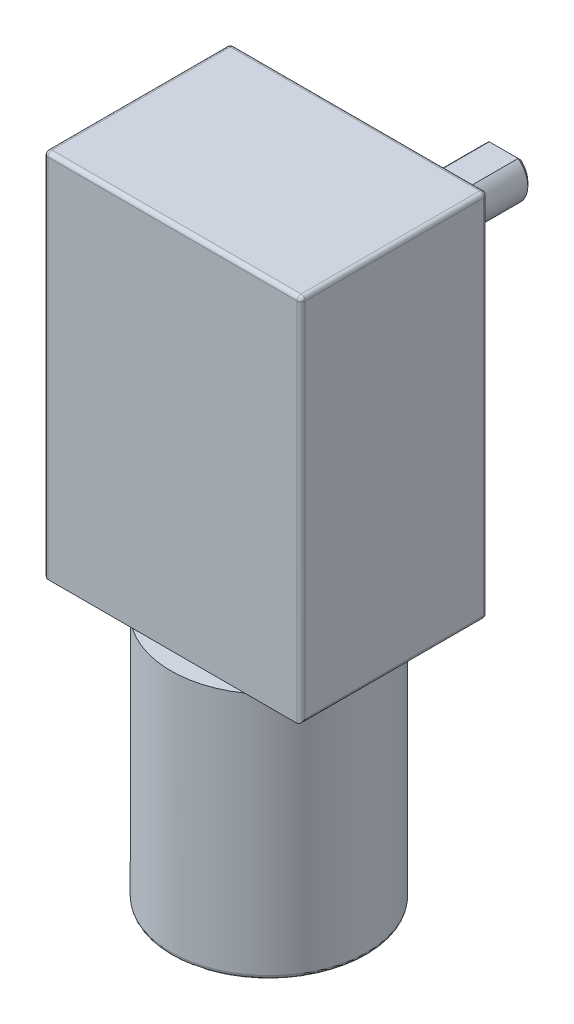
from build123d import *

# Parameters (mm, degrees)
SKETCH_1_R          = 3.5
EXTRUDE_1_DEPTH     = 3
SKETCH_2_R          = 12.2
EXTRUDE_2_DEPTH     = 30.8
SKETCH_3_W          = 32
SKETCH_3_H          = 25.2
EXTRUDE_3_DEPTH     = 46
SKETCH_4_R          = 3
EXTRUDE_4_DEPTH     = 16.5
CUT_EXTRUDE_1_DEPTH = 12
SKETCH_6_W          = 32
SKETCH_6_H          = 46
SKETCH_6_R          = 6.5
SKETCH_6_R_2        = 3
CUT_EXTRUDE_2_DEPTH = 2
FILLET_1_R          = 0.5
CHAMFER_1_SIZE      = 0.5
CHAMFER_2_SIZE      = 0.5
SKETCH_7_R          = 1.6
CUT_EXTRUDE_3_DEPTH = 4
FILLET_2_R          = 0.5


with BuildPart() as part:
    # Эскиз1 → Бобышка-Вытянуть1 (new body)
    with BuildSketch(Plane(origin=(0, 0, 0), x_dir=(1, 0, 0), z_dir=(0, 1, 0))):
        Circle(SKETCH_1_R)
    extrude(amount=EXTRUDE_1_DEPTH)

    # Эскиз2 → Бобышка-Вытянуть2 (add)
    with BuildSketch(Plane(origin=(0, 3, 0), x_dir=(1, 0, 0), z_dir=(0, 1, 0))):
        Circle(SKETCH_2_R)
    extrude(amount=EXTRUDE_2_DEPTH)

    # Эскиз3 → Бобышка-Вытянуть3 (add)
    with BuildSketch(Plane(origin=(0, 33.8, 0), x_dir=(1, 0, 0), z_dir=(0, 1, 0))):
        with Locations((-2, 2.6)):
            Rectangle(SKETCH_3_W, SKETCH_3_H)
    extrude(amount=EXTRUDE_3_DEPTH)

    # Эскиз4 → Бобышка-Вытянуть4 (add)
    with BuildSketch(Plane(origin=(0, 0, -15.2), x_dir=(-1, 0, 0), z_dir=(0, 0, -1))):
        with Locations((2, 64.8)):
            Circle(SKETCH_4_R)
    extrude(amount=EXTRUDE_4_DEPTH)

    # Эскиз5 → Вырез-Вытянуть1 (cut)
    with BuildSketch(Plane(origin=(0, 0, -31.7), x_dir=(-1, 0, 0), z_dir=(0, 0, -1))):
        with BuildLine():
            Line((0.2, 67.2), (3.8, 67.2))
            ThreePointArc((3.8, 67.2), (2, 67.8), (0.2, 67.2))
        make_face()
    extrude(amount=-CUT_EXTRUDE_1_DEPTH, mode=Mode.SUBTRACT)

    # Эскиз6 → Вырез-Вытянуть2 (cut)
    with BuildSketch(Plane(origin=(0, 0, -15.2), x_dir=(-1, 0, 0), z_dir=(0, 0, -1))):
        with Locations((2, 56.8)):
            Rectangle(SKETCH_6_W, SKETCH_6_H)
        with Locations((2, 64.8)):
            Circle(SKETCH_6_R, mode=Mode.SUBTRACT)
        with Locations((11, 40.8)):
            Circle(SKETCH_6_R_2, mode=Mode.SUBTRACT)
        with Locations((-7, 40.8)):
            Circle(SKETCH_6_R_2, mode=Mode.SUBTRACT)
        with Locations((-7, 73.8)):
            Circle(SKETCH_6_R_2, mode=Mode.SUBTRACT)
        with Locations((11, 73.8)):
            Circle(SKETCH_6_R_2, mode=Mode.SUBTRACT)
        with BuildLine():
            ThreePointArc((8.167925211, 49.8), (11.167925211, 52.8), (8.167925211, 55.8))
            Line((8.167925211, 55.8), (-4.167925211, 55.8))
            ThreePointArc((-4.167925211, 55.8), (-7.167925211, 52.8), (-4.167925211, 49.8))
            Line((-4.167925211, 49.8), (8.167925211, 49.8))
        make_face(mode=Mode.SUBTRACT)
    extrude(amount=-CUT_EXTRUDE_2_DEPTH, mode=Mode.SUBTRACT)

    # Скругление1
    fillet_1_edges = [part.edges().sort_by_distance(p)[0] for p in [
        (-11.167925211, 52.8, -15.2),
        (7.167925211, 52.8, -15.2),
        (-8, 73.8, -15.2),
        (10, 73.8, -15.2),
        (10, 40.8, -15.2),
        (4.5, 64.8, -15.2),
        (-2, 49.8, -15.2),
        (4.5, 64.8, -13.2),
        (-8, 40.8, -13.2),
        (-2, 55.8, -15.2),
    ]]
    fillet(fillet_1_edges, radius=FILLET_1_R)

    # Фаска1
    chamfer_1_edges = [part.edges().sort_by_distance(p)[0] for p in [
        (-0.658359214, 62.116718427, -31.7),
    ]]
    chamfer(chamfer_1_edges, length=CHAMFER_1_SIZE)

    # Фаска2
    chamfer_2_edges = [part.edges().sort_by_distance(p)[0] for p in [
        (-2, 67.2, -31.7),
    ]]
    chamfer(chamfer_2_edges, length=CHAMFER_2_SIZE)

    # Эскиз7 → Вырез-Вытянуть3 (cut)
    with BuildSketch(Plane(origin=(0, 0, -15.2), x_dir=(-1, 0, 0), z_dir=(0, 0, -1))):
        with Locations((11, 73.8)):
            Circle(SKETCH_7_R)
        with Locations((-7, 73.8)):
            Circle(SKETCH_7_R)
        with Locations((-7, 40.8)):
            Circle(SKETCH_7_R)
        with Locations((11, 40.8)):
            Circle(SKETCH_7_R)
    extrude(amount=-CUT_EXTRUDE_3_DEPTH, mode=Mode.SUBTRACT)

    # Скругление2
    fillet_2_edges = [part.edges().sort_by_distance(p)[0] for p in [
        (-18, 56.8, 10),
        (14, 33.8, -1.6),
        (14, 56.8, 10),
        (-2, 79.8, 10),
        (14, 79.8, -1.6),
        (-3.5, 0, 0),
        (-18, 79.8, -1.6),
        (-18, 33.8, -1.6),
        (14, 56.8, -13.2),
        (-2, 79.8, -13.2),
        (-18, 56.8, -13.2),
        (-2, 33.8, -13.2),
        (-12.2, 3, 0),
    ]]
    fillet(fillet_2_edges, radius=FILLET_2_R)


solid = part.part
